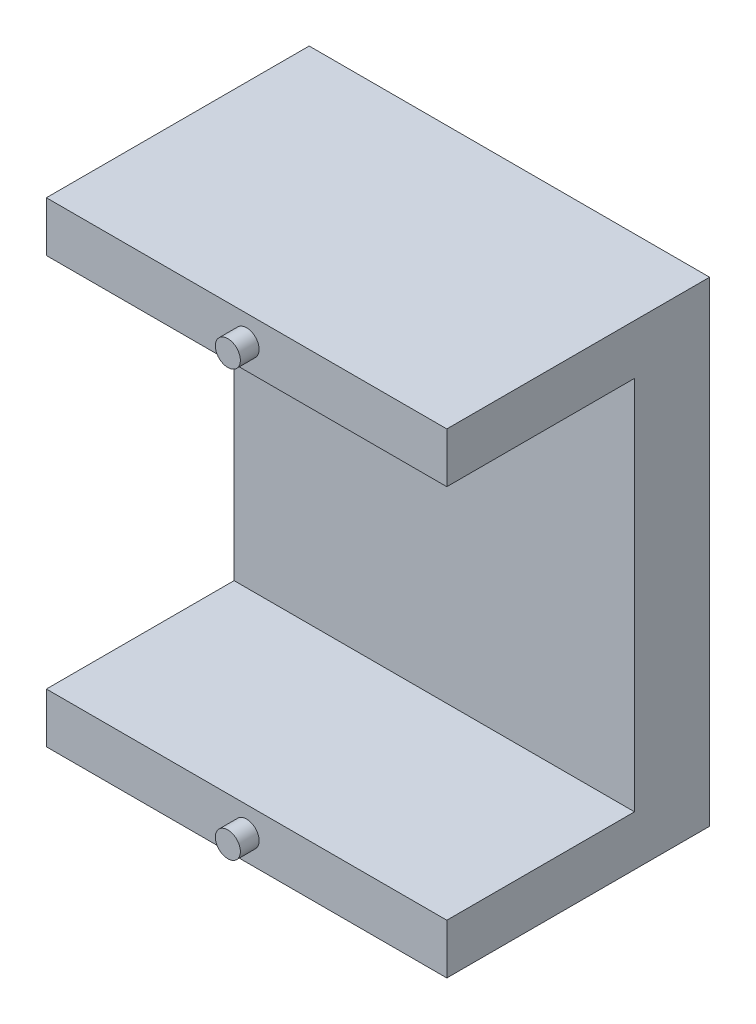
from build123d import *

# Parameters (mm, degrees)
BOSS_EXTRUDE1_DEPTH = 16
SKETCH4_R           = 1
BOSS_EXTRUDE2_DEPTH = 1.5


with BuildPart() as part:
    # Sketch3 → Boss-Extrude1 (new body, symmetric)
    with BuildSketch(Plane(origin=(0, 0, 0), x_dir=(0, 0, -1), z_dir=(1, 0, 0))):
        Polygon((0, 0), (0, 4), (15, 4), (15, 34), (0, 34), (0, 38), (21, 38), (21, 0), align=None)
    extrude(amount=BOSS_EXTRUDE1_DEPTH, both=True)

    # Sketch4 → Boss-Extrude2 (add, symmetric)
    with BuildSketch(Plane.XY):
        with Locations((0, 36)):
            Circle(SKETCH4_R)
        with Locations((0, 2)):
            Circle(SKETCH4_R)
    extrude(amount=BOSS_EXTRUDE2_DEPTH, both=True)


solid = part.part
